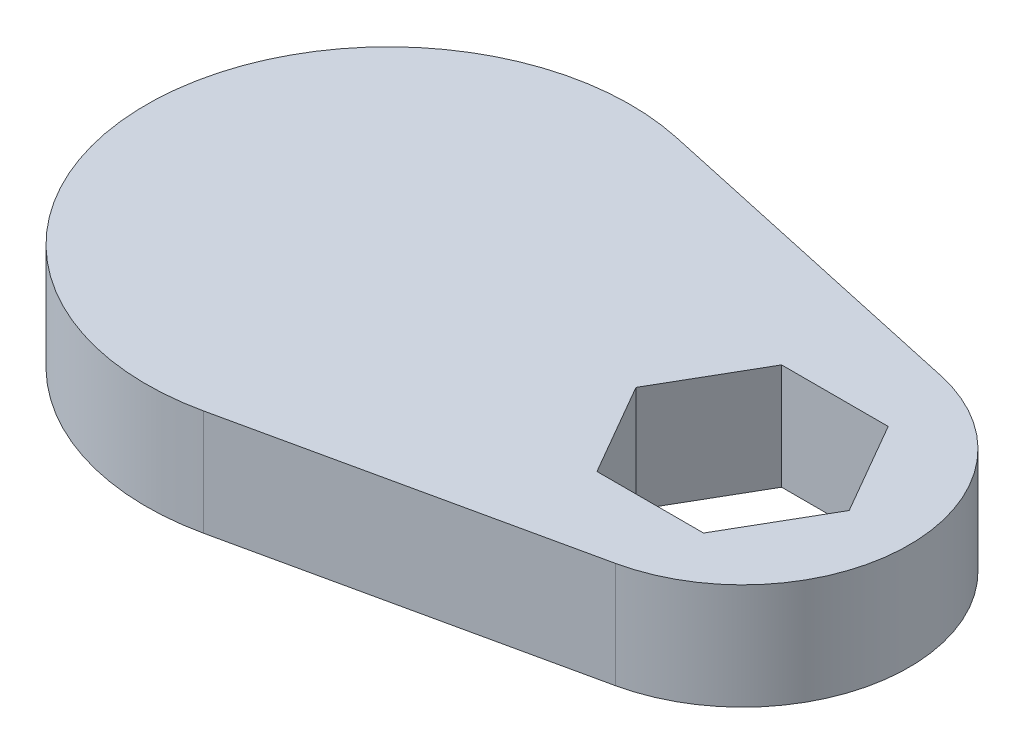
from build123d import *

# Parameters (mm, degrees)
SKETCH1_R           = 12
BOSS_EXTRUDE1_DEPTH = 7
SKETCH1_4_R         = 12
CUT_EXTRUDE1_DEPTH  = 2.3


with BuildPart() as part:
    # Sketch1 → Boss-Extrude1 (new body)
    with BuildSketch(Plane(origin=(0, 0, 0), x_dir=(1, 0, 0), z_dir=(0, 1, 0))):
        with BuildLine():
            ThreePointArc((14.05042735, 10.74595232), (22.7, 0), (14.05042735, -10.74595232))
            Line((14.05042735, -10.74595232), (-8.281196581, -15.630476102))
            ThreePointArc((-8.281196581, -15.630476102), (-27.7, 0), (-8.281196581, 15.630476102))
            Line((-8.281196581, 15.630476102), (14.05042735, 10.74595232))
        make_face()
        with Locations((-11.7, 0)):
            Circle(SKETCH1_R, mode=Mode.SUBTRACT)
        Polygon((15.221836642, -6.1), (18.743673284, 0), (15.221836642, 6.1), (8.178163358, 6.1), (4.656326716, 0), (8.178163358, -6.1), align=None, mode=Mode.SUBTRACT)
        with Locations((-11.7, 0)):
            Circle(SKETCH1_R)
    extrude(amount=BOSS_EXTRUDE1_DEPTH)

    # Sketch1_4 → Cut-Extrude1 (cut)
    with BuildSketch(Plane(origin=(0, 0, 0), x_dir=(1, 0, 0), z_dir=(0, 1, 0))):
        with Locations(Location((-11.7, 0, 0), (0, 0, 270))):  # turned: the seam where the file's is
            Circle(SKETCH1_4_R)
    extrude(amount=CUT_EXTRUDE1_DEPTH, mode=Mode.SUBTRACT)


solid = part.part
